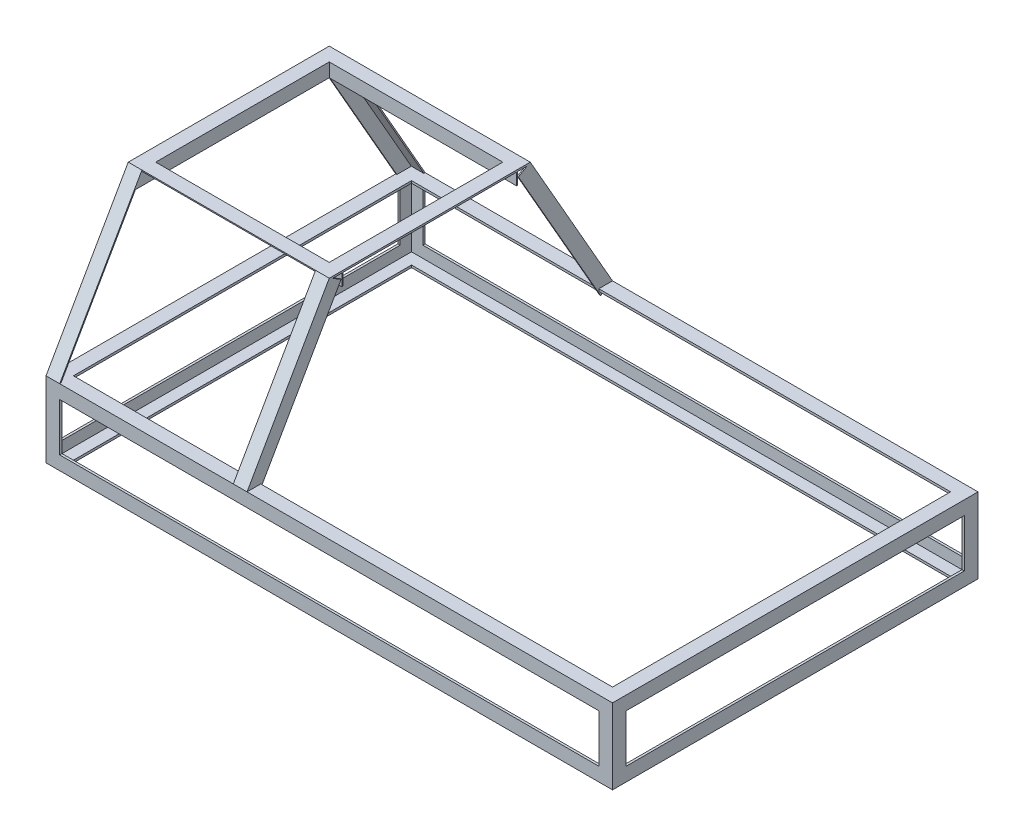
from build123d import *

# Parameters (mm, degrees)
BOTTOM_HORIZONTAL_ANGLE_DEPTH   = 1574.8
BOTTOM_HORIZONTAL_ANGLE_2_DEPTH = 1574.8
BOTTOM_HORIZONTAL_ANGLE_3_DEPTH = 1574.8
BOTTOM_HORIZONTAL_ANGLE_4_DEPTH = 1574.8
FRONT_VERTIAL_ANGLE_DEPTH       = 209.55
REAR_DIAGONAL_ANGLE_DEPTH       = 460.75803
REAR_TOP_ANGLE_REACH            = 510
REAR_TOP_HORIZONTAL_ANGLE_DEPTH = 558.8
BOSS_EXTRUDE9_START             = -469.9
BOSS_EXTRUDE9_DEPTH             = 939.8


with BuildPart() as part:
    # Sketch5 → Bottom Horizontal Angle (new body)
    with BuildSketch(Plane(origin=(0, 0, 0), x_dir=(0, 0, -1), z_dir=(1, 0, 0))):
        Polygon((-508, -304.8), (-508, -266.7), (-501.65, -266.7), (-501.65, -298.45), (-469.9, -298.45), (-469.9, -304.8), align=None)
    extrude(amount=BOTTOM_HORIZONTAL_ANGLE_DEPTH)



with BuildPart() as body_2:
    # Sketch5 → Bottom Horizontal Angle 2 (new body)
    with BuildSketch(Plane(origin=(0, 0, 0), x_dir=(0, 0, -1), z_dir=(1, 0, 0))):
        Polygon((501.65, -266.7), (508, -266.7), (508, -304.8), (469.9, -304.8), (469.9, -298.45), (501.65, -298.45), align=None)
    extrude(amount=BOTTOM_HORIZONTAL_ANGLE_2_DEPTH)


with BuildPart() as body_3:
    # Sketch5 → Bottom Horizontal Angle 3 (new body)
    with BuildSketch(Plane(origin=(0, 0, 0), x_dir=(0, 0, -1), z_dir=(1, 0, 0))):
        Polygon((508, -95.25), (508, -133.35), (501.65, -133.35), (501.65, -101.6), (469.9, -101.6), (469.9, -95.25), align=None)
    extrude(amount=BOTTOM_HORIZONTAL_ANGLE_3_DEPTH)


with BuildPart() as body_4:
    # Sketch5 → Bottom Horizontal Angle 4 (new body)
    with BuildSketch(Plane(origin=(0, 0, 0), x_dir=(0, 0, -1), z_dir=(1, 0, 0))):
        Polygon((-501.65, -133.35), (-508, -133.35), (-508, -95.25), (-469.9, -95.25), (-469.9, -101.6), (-501.65, -101.6), align=None)
    extrude(amount=BOTTOM_HORIZONTAL_ANGLE_4_DEPTH)


with BuildPart() as part_1:
    add(part.part)

    add(body_2.part)  # Front Vertial Angle merges body 2

    add(body_3.part)  # Front Vertial Angle merges body 3

    add(body_4.part)  # Front Vertial Angle merges body 4
    # Sketch6 → Front Vertial Angle (add)
    with BuildSketch(Plane.XZ.offset(304.8)):
        Polygon((1574.8, -508), (1536.7, -508), (1536.7, -501.65), (1568.45, -501.65), (1568.45, -469.9), (1574.8, -469.9), align=None)
        Polygon((1536.7, 501.65), (1536.7, 508), (1574.8, 508), (1574.8, 469.9), (1568.45, 469.9), (1568.45, 501.65), align=None)
        Polygon((0, 508), (38.1, 508), (38.1, 501.65), (6.35, 501.65), (6.35, 469.9), (0, 469.9), align=None)
        Polygon((38.1, -501.65), (38.1, -508), (0, -508), (0, -469.9), (6.35, -469.9), (6.35, -501.65), align=None)
    extrude(amount=-FRONT_VERTIAL_ANGLE_DEPTH)

    # Sketch13 → Rear Diagonal Angle (add)
    with BuildSketch(Plane(origin=(0, -95.25, 508), x_dir=(-1, 0, 0), z_dir=(0, -0.868243142, 0.496138938))):
        Polygon((0, 0), (0, 38.1), (-3.175, 38.1), (-3.175, 3.175), (-38.1, 3.175), (-38.1, 0), align=None)
        Polygon((-520.7, 0), (-558.8, 0), (-558.8, 38.1), (-555.625, 38.1), (-555.625, 3.175), (-520.7, 3.175), align=None)
    extrude(amount=-REAR_DIAGONAL_ANGLE_DEPTH)

    # Sketch14 → Rear Top Angle (add, up to next)
    with BuildSketch(Plane.XY, mode=Mode.PRIVATE) as rear_top_angle_sk1:
        Polygon((33.02, 266.7), (38.1, 266.7), (38.1, 304.8), (0, 304.8), (0, 299.72), (33.02, 299.72), align=None)
    rear_top_angle_tool1 = extrude(rear_top_angle_sk1.sketch, amount=REAR_TOP_ANGLE_REACH, mode=Mode.PRIVATE) - part_1.part
    add(rear_top_angle_tool1.solids().sort_by_distance((35.56, 267.238815, 0))[0])
    # Sketch14 → Rear Top Angle (add, up to next)
    with BuildSketch(Plane.XY, mode=Mode.PRIVATE) as rear_top_angle_sk2:
        Polygon((525.78, 299.72), (525.78, 266.7), (520.7, 266.7), (520.7, 304.8), (558.8, 304.8), (558.8, 299.72), align=None)
    rear_top_angle_tool2 = extrude(rear_top_angle_sk2.sketch, amount=REAR_TOP_ANGLE_REACH, mode=Mode.PRIVATE) - part_1.part
    add(rear_top_angle_tool2.solids().sort_by_distance((525.241185, 283.21, 0))[0])

    # Sketch8 → Rear Top Horizontal Angle (add)
    with BuildSketch(Plane.ZY):
        Polygon((244.475, 266.7), (241.3, 266.7), (241.3, 304.8), (279.4, 304.8), (279.4, 301.625), (244.475, 301.625), align=None)
    extrude(amount=-REAR_TOP_HORIZONTAL_ANGLE_DEPTH)

    # Sketch15 → Boss-Extrude9 (add)
    with BuildSketch(Plane.XY.offset(BOSS_EXTRUDE9_START)):
        Polygon((0, -266.7), (0, -304.8), (38.1, -304.8), (38.1, -298.45), (6.35, -298.45), (6.35, -266.7), align=None)
        Polygon((1568.45, -266.7), (1574.8, -266.7), (1574.8, -304.8), (1536.7, -304.8), (1536.7, -298.45), (1568.45, -298.45), align=None)
        Polygon((1574.8, -133.35), (1574.8, -95.25), (1536.7, -95.25), (1536.7, -101.6), (1568.45, -101.6), (1568.45, -133.35), align=None)
        Polygon((6.35, -133.35), (0, -133.35), (0, -95.25), (38.1, -95.25), (38.1, -101.6), (6.35, -101.6), align=None)
    extrude(amount=BOSS_EXTRUDE9_DEPTH)

    # Mirror 2: part across plane


with BuildPart() as part_2:
    add(part_1.part)
    add(part_1.part.mirror(Plane.XY))


solid = part_2.part
